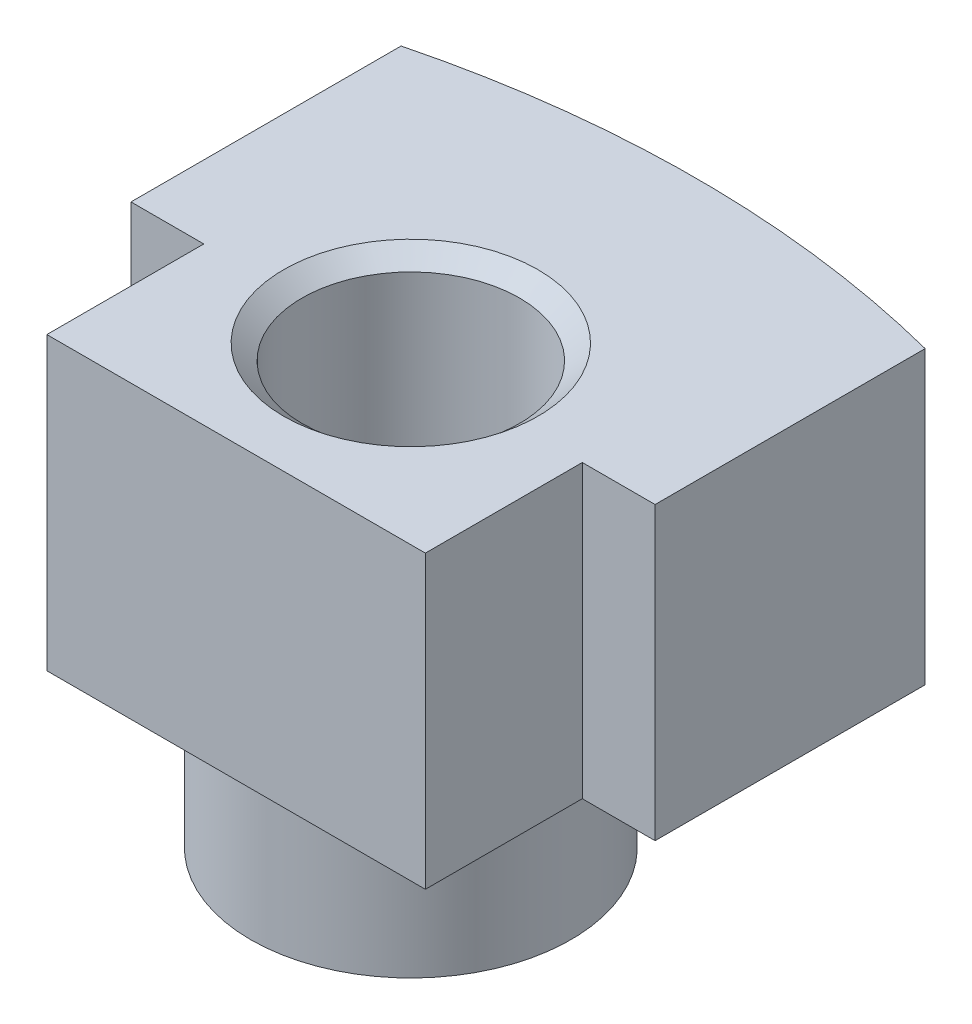
from build123d import *

# Parameters (mm, degrees)
BOSS_EXTRUDE1_DEPTH                    = 25.4
SKETCH21_R                             = 13.97
BOSS_EXTRUDE2_DEPTH                    = 12.7
F_1_2_14_NPSM_TAPPED_HOLE1_D           = 18.9738
F_1_2_14_NPSM_TAPPED_HOLE1_DEPTH       = 25.4
F_1_2_14_NPSM_TAPPED_HOLE1_CSINK_D     = 22.1742
F_1_2_14_NPSM_TAPPED_HOLE1_CSINK_ANGLE = 100
F_1_2_14_NPSM_TAPPED_HOLE1_TIP         = 5.700304607


with BuildPart() as part:
    # Sketch1 → Boss-Extrude1 (new body)
    with BuildSketch(Plane(origin=(0, 0, 0), x_dir=(1, 0, 0), z_dir=(0, 1, 0))):
        with BuildLine():
            Line((-16.51, -37.249073779), (16.51, -37.249073779))
            Line((16.51, -37.249073779), (16.51, -23.558908882))
            Line((16.51, -23.558908882), (22.86, -23.558908882))
            Line((22.86, -23.558908882), (22.86, 0))
            ThreePointArc((22.86, 0), (0, 2.882926221), (-22.86, 0))
            Line((-22.86, 0), (-22.86, -23.558908882))
            Line((-22.86, -23.558908882), (-16.51, -23.558908882))
            Line((-16.51, -23.558908882), (-16.51, -37.249073779))
        make_face()
    extrude(amount=BOSS_EXTRUDE1_DEPTH)

    # Sketch21 → Boss-Extrude2 (add)
    with BuildSketch(Plane.XZ):
        with Locations((0, 22.009073779)):
            Circle(SKETCH21_R)
    extrude(amount=BOSS_EXTRUDE2_DEPTH)

    # 1/2-14 NPSM Tapped Hole1
    with Locations(Plane(origin=(0, 25.4, 0), x_dir=(1, 0, 0), z_dir=(0, 1, 0))):
        with Locations((0, -22.009073779)):
            CounterSinkHole(F_1_2_14_NPSM_TAPPED_HOLE1_D / 2, F_1_2_14_NPSM_TAPPED_HOLE1_CSINK_D / 2, depth=F_1_2_14_NPSM_TAPPED_HOLE1_DEPTH, counter_sink_angle=F_1_2_14_NPSM_TAPPED_HOLE1_CSINK_ANGLE)
            with Locations((0, 0, -(F_1_2_14_NPSM_TAPPED_HOLE1_DEPTH + F_1_2_14_NPSM_TAPPED_HOLE1_TIP / 2))):  # 118° drill point
                Cone(0, F_1_2_14_NPSM_TAPPED_HOLE1_D / 2, F_1_2_14_NPSM_TAPPED_HOLE1_TIP, mode=Mode.SUBTRACT)

    # Sketch26 → Tap Drill for #8-32 Tap1 (revolve, cut)
    with BuildSketch(Plane(origin=(-15.988655959, 12.7, -2.75410008), x_dir=(0, 1, 0), z_dir=(1, 0, 0))):
        Polygon((0, 0), (0, 22.373806461), (1.7272, 21.336), (1.7272, 0), align=None)
    tap_drill_for_8_32_tap1 = revolve(axis=Axis((-15.988655959, 12.7, -9.10410008), (0, 0, 1)), mode=Mode.SUBTRACT)

    # Mirror1: Tap Drill for #8-32 Tap1 across plane
    add(tap_drill_for_8_32_tap1.mirror(Plane(origin=(0, 0, 0), x_dir=(0, 0, 1), z_dir=(1, 0, 0))), mode=Mode.SUBTRACT)


solid = part.part
